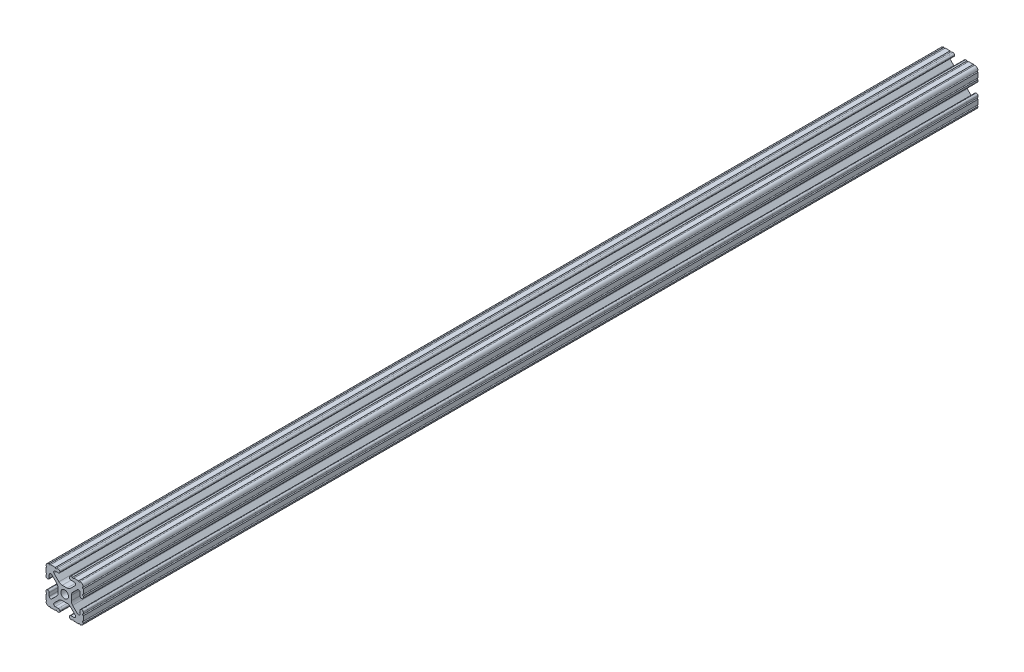
from build123d import *

# Parameters (mm, degrees)
SKETCH1_R               = 2.6035
BOSS_EXTRUDE1_DEPTH     = 393.7
SKETCH3_W               = 38.454508912
SKETCH3_H               = 36.401112806
CUT_EXTRUDE2_DEPTH      = 177.8
SKETCH4_R               = 3.18
CUT_EXTRUDE3_DEPTH      = 9.1915
CUT_EXTRUDE3_DEPTH_BACK = 18.2085


with BuildPart() as part:
    # Sketch1 → Boss-Extrude1 (new body, symmetric)
    with BuildSketch(Plane.XY):
        with BuildLine():
            Line((-7.179650497, -8.645192506), (-3.952270251, -5.423690499))
            ThreePointArc((-3.952270251, -5.423690499), (-2.922936451, -4.736929036), (-1.709253557, -4.4958))
            Line((-1.709253557, -4.4958), (1.709253557, -4.4958))
            ThreePointArc((1.709253557, -4.4958), (2.922936451, -4.736929036), (3.952270251, -5.423690499))
            Line((3.952270251, -5.423690499), (7.179650497, -8.645192506))
            ThreePointArc((7.179650497, -8.645192506), (7.41473083, -9.822813117), (6.416408329, -10.4902))
            Line((6.416408329, -10.4902), (4.287512407, -10.4902))
            ThreePointArc((4.287512407, -10.4902), (3.54574862, -10.79744862), (3.2385, -11.539212407))
            Line((3.2385, -11.539212407), (3.2385, -11.650987593))
            ThreePointArc((3.2385, -11.650987593), (3.54574862, -12.39275138), (4.287512407, -12.7))
            Line((4.287512407, -12.7), (5.317126718, -12.7))
            ThreePointArc((5.317126718, -12.7), (5.825126718, -12.192), (6.333126718, -12.7))
            Line((6.333126718, -12.7), (9.550443118, -12.7))
            ThreePointArc((9.550443118, -12.7), (10.058366869, -12.192000006), (10.566443095, -12.699847501))
            ThreePointArc((10.566443095, -12.699847501), (12.082537762, -12.08250727), (12.699846982, -10.566399977))
            ThreePointArc((12.699846982, -10.566399977), (12.192000006, -10.058323491), (12.7, -9.5504))
            Line((12.7, -9.5504), (12.7, -6.3330836))
            ThreePointArc((12.7, -6.3330836), (12.192, -5.8250836), (12.7, -5.3170836))
            Line((12.7, -5.3170836), (12.7, -4.287469289))
            ThreePointArc((12.7, -4.287469289), (12.39275138, -3.545705502), (11.650987593, -3.238456882))
            Line((11.650987593, -3.238456882), (11.539212407, -3.238456882))
            ThreePointArc((11.539212407, -3.238456882), (10.79744862, -3.545705502), (10.4902, -4.287469289))
            Line((10.4902, -4.287469289), (10.4902, -6.402089023))
            ThreePointArc((10.4902, -6.402089023), (9.856505071, -7.351067942), (8.737131347, -7.129408934))
            Line((8.737131347, -7.129408934), (5.441005833, -3.840816462))
            ThreePointArc((5.441005833, -3.840816462), (4.750877967, -2.809883091), (4.5085, -1.593185507))
            Line((4.5085, -1.593185507), (4.5085, 1.593185507))
            ThreePointArc((4.5085, 1.593185507), (4.750877967, 2.809883091), (5.441005833, 3.840816462))
            Line((5.441005833, 3.840816462), (8.737131347, 7.129408934))
            ThreePointArc((8.737131347, 7.129408934), (9.856505071, 7.351067942), (10.4902, 6.402089023))
            Line((10.4902, 6.402089023), (10.4902, 4.287469289))
            ThreePointArc((10.4902, 4.287469289), (10.79744862, 3.545705502), (11.539212407, 3.238456882))
            Line((11.539212407, 3.238456882), (11.650987593, 3.238456882))
            ThreePointArc((11.650987593, 3.238456882), (12.39275138, 3.545705502), (12.7, 4.287469289))
            Line((12.7, 4.287469289), (12.7, 5.3170836))
            ThreePointArc((12.7, 5.3170836), (12.192, 5.8250836), (12.7, 6.3330836))
            Line((12.7, 6.3330836), (12.7, 9.5504))
            ThreePointArc((12.7, 9.5504), (12.192000006, 10.058323491), (12.699846982, 10.566399977))
            ThreePointArc((12.699846982, 10.566399977), (12.082537762, 12.08250727), (10.566443095, 12.699847501))
            ThreePointArc((10.566443095, 12.699847501), (10.058366869, 12.192000006), (9.550443118, 12.7))
            Line((9.550443118, 12.7), (6.333126718, 12.7))
            ThreePointArc((6.333126718, 12.7), (5.825126718, 12.192), (5.317126718, 12.7))
            Line((5.317126718, 12.7), (4.287512407, 12.7))
            ThreePointArc((4.287512407, 12.7), (3.54574862, 12.39275138), (3.2385, 11.650987593))
            Line((3.2385, 11.650987593), (3.2385, 11.539212407))
            ThreePointArc((3.2385, 11.539212407), (3.54574862, 10.79744862), (4.287512407, 10.4902))
            Line((4.287512407, 10.4902), (6.476788598, 10.4902))
            ThreePointArc((6.476788598, 10.4902), (7.432222385, 9.85140422), (7.207036008, 8.724370562))
            Line((7.207036008, 8.724370562), (3.898272566, 5.423169045))
            ThreePointArc((3.898272566, 5.423169045), (2.869120213, 4.736787962), (1.655778399, 4.4958))
            Line((1.655778399, 4.4958), (-1.655778399, 4.4958))
            ThreePointArc((-1.655778399, 4.4958), (-2.869120213, 4.736787962), (-3.898272566, 5.423169045))
            Line((-3.898272566, 5.423169045), (-7.207036008, 8.724370562))
            ThreePointArc((-7.207036008, 8.724370562), (-7.432222385, 9.85140422), (-6.476788598, 10.4902))
            Line((-6.476788598, 10.4902), (-4.287512407, 10.4902))
            ThreePointArc((-4.287512407, 10.4902), (-3.54574862, 10.79744862), (-3.2385, 11.539212407))
            Line((-3.2385, 11.539212407), (-3.2385, 11.650987593))
            ThreePointArc((-3.2385, 11.650987593), (-3.54574862, 12.39275138), (-4.287512407, 12.7))
            Line((-4.287512407, 12.7), (-5.317126718, 12.7))
            ThreePointArc((-5.317126718, 12.7), (-5.825126718, 12.192), (-6.333126718, 12.7))
            Line((-6.333126718, 12.7), (-9.550443118, 12.7))
            ThreePointArc((-9.550443118, 12.7), (-10.058366869, 12.192000006), (-10.566443095, 12.699847501))
            ThreePointArc((-10.566443095, 12.699847501), (-12.082537762, 12.08250727), (-12.699846982, 10.566399977))
            ThreePointArc((-12.699846982, 10.566399977), (-12.192000006, 10.058323491), (-12.7, 9.5504))
            Line((-12.7, 9.5504), (-12.7, 6.3330836))
            ThreePointArc((-12.7, 6.3330836), (-12.192, 5.8250836), (-12.7, 5.3170836))
            Line((-12.7, 5.3170836), (-12.7, 4.287469289))
            ThreePointArc((-12.7, 4.287469289), (-12.39275138, 3.545705502), (-11.650987593, 3.238456882))
            Line((-11.650987593, 3.238456882), (-11.539212407, 3.238456882))
            ThreePointArc((-11.539212407, 3.238456882), (-10.79744862, 3.545705502), (-10.4902, 4.287469289))
            Line((-10.4902, 4.287469289), (-10.4902, 6.402089023))
            ThreePointArc((-10.4902, 6.402089023), (-9.856505071, 7.351067942), (-8.737131347, 7.129408934))
            Line((-8.737131347, 7.129408934), (-5.441005833, 3.840816462))
            ThreePointArc((-5.441005833, 3.840816462), (-4.750877967, 2.809883091), (-4.5085, 1.593185507))
            Line((-4.5085, 1.593185507), (-4.5085, -1.593185507))
            ThreePointArc((-4.5085, -1.593185507), (-4.750877967, -2.809883091), (-5.441005833, -3.840816462))
            Line((-5.441005833, -3.840816462), (-8.737131347, -7.129408934))
            ThreePointArc((-8.737131347, -7.129408934), (-9.856505071, -7.351067942), (-10.4902, -6.402089023))
            Line((-10.4902, -6.402089023), (-10.4902, -4.287469289))
            ThreePointArc((-10.4902, -4.287469289), (-10.79744862, -3.545705502), (-11.539212407, -3.238456882))
            Line((-11.539212407, -3.238456882), (-11.650987593, -3.238456882))
            ThreePointArc((-11.650987593, -3.238456882), (-12.39275138, -3.545705502), (-12.7, -4.287469289))
            Line((-12.7, -4.287469289), (-12.7, -5.3170836))
            ThreePointArc((-12.7, -5.3170836), (-12.192, -5.8250836), (-12.7, -6.3330836))
            Line((-12.7, -6.3330836), (-12.7, -9.5504))
            ThreePointArc((-12.7, -9.5504), (-12.192000006, -10.058323491), (-12.699846982, -10.566399977))
            ThreePointArc((-12.699846982, -10.566399977), (-12.082537762, -12.08250727), (-10.566443095, -12.699847501))
            ThreePointArc((-10.566443095, -12.699847501), (-10.058366869, -12.192000006), (-9.550443118, -12.7))
            Line((-9.550443118, -12.7), (-6.333126718, -12.7))
            ThreePointArc((-6.333126718, -12.7), (-5.825126718, -12.192), (-5.317126718, -12.7))
            Line((-5.317126718, -12.7), (-4.287512407, -12.7))
            ThreePointArc((-4.287512407, -12.7), (-3.54574862, -12.39275138), (-3.2385, -11.650987593))
            Line((-3.2385, -11.650987593), (-3.2385, -11.539212407))
            ThreePointArc((-3.2385, -11.539212407), (-3.54574862, -10.79744862), (-4.287512407, -10.4902))
            Line((-4.287512407, -10.4902), (-6.416408329, -10.4902))
            ThreePointArc((-6.416408329, -10.4902), (-7.41473083, -9.822813117), (-7.179650497, -8.645192506))
        make_face()
        Circle(SKETCH1_R, mode=Mode.SUBTRACT)
    extrude(amount=BOSS_EXTRUDE1_DEPTH, both=True)

    # Sketch3 → Cut-Extrude2 (cut)
    with BuildSketch(Plane.XY.offset(393.7)):
        Rectangle(SKETCH3_W, SKETCH3_H)
    extrude(amount=-CUT_EXTRUDE2_DEPTH, mode=Mode.SUBTRACT)

    # Sketch4 → Cut-Extrude3 (cut, two sides)
    with BuildSketch(Plane(origin=(4.5085, 0, 0), x_dir=(0, 0, -1), z_dir=(1, 0, 0))) as cut_extrude3_sk:
        with Locations((374.65, -0.000152499)):
            Circle(SKETCH4_R)
        with Locations((-196.85, -0.000152499)):
            Circle(SKETCH4_R)
    extrude(amount=CUT_EXTRUDE3_DEPTH, mode=Mode.SUBTRACT)
    extrude(cut_extrude3_sk.sketch, amount=-CUT_EXTRUDE3_DEPTH_BACK, mode=Mode.SUBTRACT)


solid = part.part
